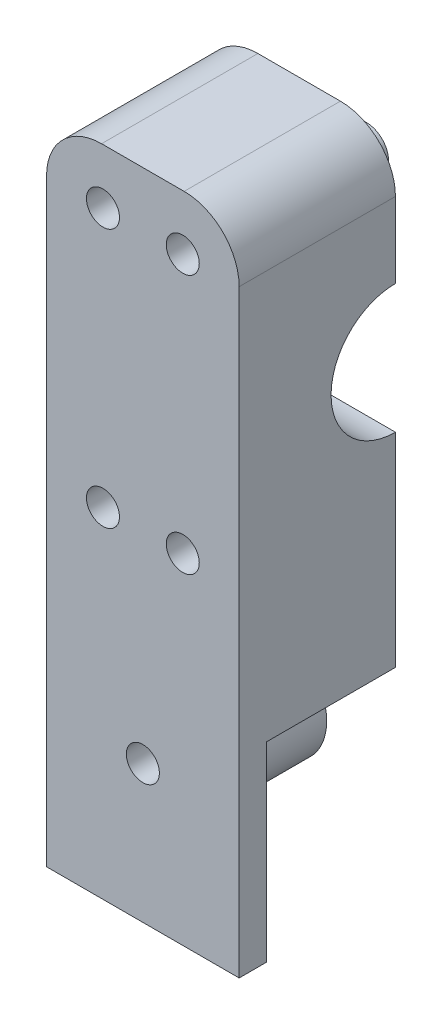
from build123d import *

# Parameters (mm, degrees)
SKETCH1_R               = 11.7
BOSS_EXTRUDE1_DEPTH     = 35
SKETCH2_R               = 10
BOSS_EXTRUDE3_DEPTH     = 51.8
SKETCH3_R               = 3
CUT_EXTRUDE1_DEPTH      = 90.32860684
CUT_EXTRUDE1_DEPTH_BACK = 90.32860684
SKETCH6_W               = 28.4
SKETCH6_H               = 118.8
CUT_EXTRUDE3_DEPTH      = 75.564871086
SKETCH8_R               = 10
SKETCH8_R_2             = 3
CUT_EXTRUDE4_DEPTH      = 5
SKETCH7_R               = 4
SKETCH7_R_2             = 3
BOSS_EXTRUDE4_DEPTH     = 5
FILLET1_R               = 10


with BuildPart() as part:
    # Sketch1 → Boss-Extrude1 (new body)
    with BuildSketch(Plane(origin=(0, 0, 0), x_dir=(0, 0, -1), z_dir=(1, 0, 0))):
        Polygon((-28.4, -59.4), (-23.4, -59.4), (-23.4, -14.4), (23.4, -14.4), (23.4, -59.4), (28.4, -59.4), (28.4, 59.4), (-28.4, 59.4), align=None)
        with Locations((0, 24)):
            Circle(SKETCH1_R, mode=Mode.SUBTRACT)
    extrude(amount=BOSS_EXTRUDE1_DEPTH)

    # Sketch2 → Boss-Extrude3 (add)
    with BuildSketch(Plane.XY.offset(28.4)):
        with Locations(Location((17.5, -34.4, 0), (0, 0, 90))):
            Circle(SKETCH2_R)
        with BuildLine():
            Line((0, -24.717541634), (0, -13.4))
            Line((0, -13.4), (35, -13.4))
            Line((35, -13.4), (35, -24.717541634))
            ThreePointArc((35, -24.717541634), (17.5, -14.4), (0, -24.717541634))
        make_face()
    extrude(amount=-BOSS_EXTRUDE3_DEPTH)

    # Sketch3 → Cut-Extrude1 (cut, two sides)
    with BuildSketch(Plane.XY.offset(28.4)) as cut_extrude1_sk:
        with Locations((10.25, 49.4)):
            Circle(SKETCH3_R)
        with Locations((17.5, -34.4)):
            Circle(SKETCH3_R)
        with Locations((10.25, 2.3)):
            Circle(SKETCH3_R)
        with Locations((24.75, 2.3)):
            Circle(SKETCH3_R)
        with Locations((24.75, 49.4)):
            Circle(SKETCH3_R)
    extrude(amount=CUT_EXTRUDE1_DEPTH, mode=Mode.SUBTRACT)
    extrude(cut_extrude1_sk.sketch, amount=-CUT_EXTRUDE1_DEPTH_BACK, mode=Mode.SUBTRACT)

    # Sketch6 → Cut-Extrude3 (cut, through all)
    with BuildSketch(Plane(origin=(35, 0, 0), x_dir=(0, 0, -1), z_dir=(1, 0, 0))):
        with Locations((14.2, 0)):
            Rectangle(SKETCH6_W, SKETCH6_H)
    extrude(amount=-CUT_EXTRUDE3_DEPTH, mode=Mode.SUBTRACT)

    # Sketch8 → Cut-Extrude4 (cut)
    with BuildSketch(Plane(origin=(0, 0, 0), x_dir=(-1, 0, 0), z_dir=(0, 0, -1))):
        with Locations(Location((-17.5, -34.4, 0), (0, 0, 270))):
            Circle(SKETCH8_R)
        with Locations(Location((-17.5, -34.4, 0), (0, 0, 180))):
            Circle(SKETCH8_R_2, mode=Mode.SUBTRACT)
    extrude(amount=-CUT_EXTRUDE4_DEPTH, mode=Mode.SUBTRACT)

    # Sketch7 → Boss-Extrude4 (add)
    with BuildSketch(Plane(origin=(0, 0, 0), x_dir=(-1, 0, 0), z_dir=(0, 0, -1))):
        with Locations(Location((-24.75, 49.4, 0), (0, 0, 270))):
            Circle(SKETCH7_R)
        with Locations(Location((-24.75, 49.4, 0), (0, 0, 180))):
            Circle(SKETCH7_R_2, mode=Mode.SUBTRACT)
        with Locations(Location((-10.25, 49.4, 0), (0, 0, 270))):
            Circle(SKETCH7_R)
        with Locations(Location((-10.25, 49.4, 0), (0, 0, 180))):
            Circle(SKETCH7_R_2, mode=Mode.SUBTRACT)
        with Locations(Location((-24.75, 2.3, 0), (0, 0, 270))):
            Circle(SKETCH7_R)
        with Locations(Location((-24.75, 2.3, 0), (0, 0, 180))):
            Circle(SKETCH7_R_2, mode=Mode.SUBTRACT)
        with Locations(Location((-10.25, 2.3, 0), (0, 0, 270))):
            Circle(SKETCH7_R)
        with Locations(Location((-10.25, 2.3, 0), (0, 0, 180))):
            Circle(SKETCH7_R_2, mode=Mode.SUBTRACT)
    extrude(amount=BOSS_EXTRUDE4_DEPTH)

    # Fillet1
    fillet1_edges = [part.edges().sort_by_distance(p)[0] for p in [
        (0, 59.4, 14.2),
        (35, 59.4, 14.2),
    ]]
    fillet(fillet1_edges, radius=FILLET1_R)


solid = part.part
